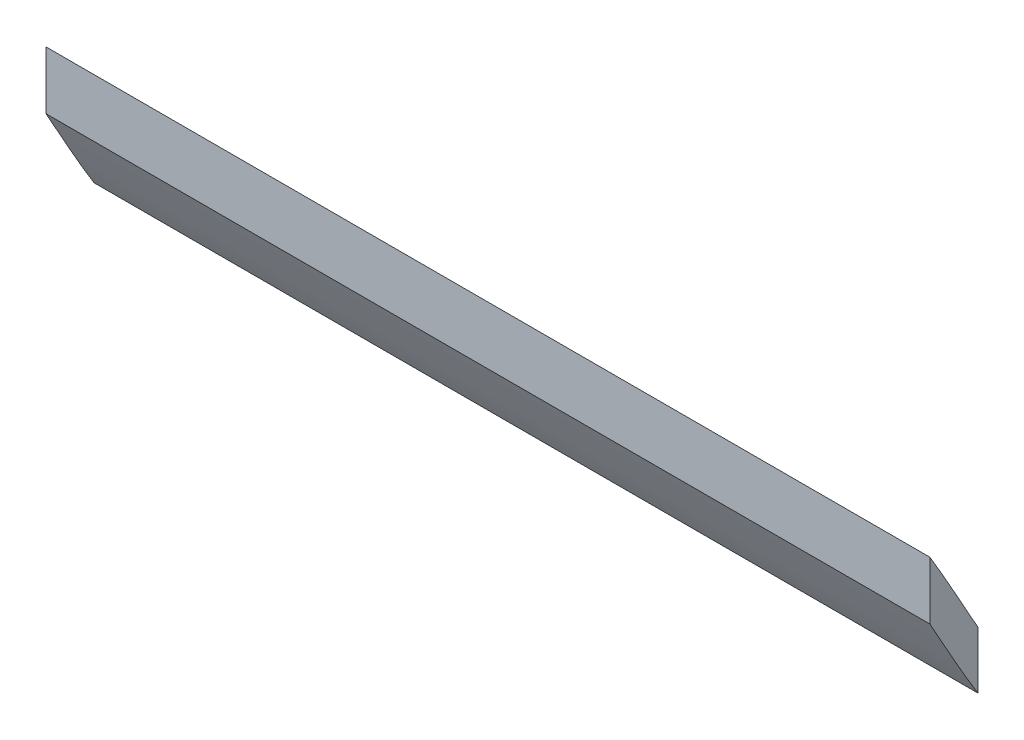
from build123d import *

# Parameters (mm, degrees)
BOSS_EXTRUDE1_DEPTH = 55


with BuildPart() as part:
    # Sketch1 → Boss-Extrude1 (new body)
    with BuildSketch(Plane(origin=(0, 0, 0), x_dir=(0, 0, -1), z_dir=(1, 0, 0))):
        with BuildLine():
            Line((-94.297393358, -47.101434774), (-94.297393358, -50.705061555))
            add(Edge.make_bspline(
                [(-94.297393358, -50.705061555), (-93.67823928, -51.812081864), (-93.067906607, -52.924415572), (-92.066192837, -54.66563879), (-91.689243803, -55.303221166), (-91.297393358, -55.931827973)],
                knots=[0.10625854, 0.10625854, 0.10625854, 0.10625854, 0.25, 0.25, 0.333977661, 0.333977661, 0.333977661, 0.333977661], degree=3))
            Line((-91.297393358, -55.931827973), (-91.297393358, -52.385434096))
            add(Edge.make_bspline(
                [(-91.297393358, -52.385434096), (-91.591962101, -51.863911266), (-91.883184972, -51.340149172), (-92.868348217, -49.570119371), (-93.562184819, -48.323615763), (-94.297393358, -47.101434774)],
                knots=[0.684770993, 0.684770993, 0.684770993, 0.684770993, 0.75, 0.75, 0.905319484, 0.905319484, 0.905319484, 0.905319484], degree=3))
        make_face()
    extrude(amount=BOSS_EXTRUDE1_DEPTH)


solid = part.part
